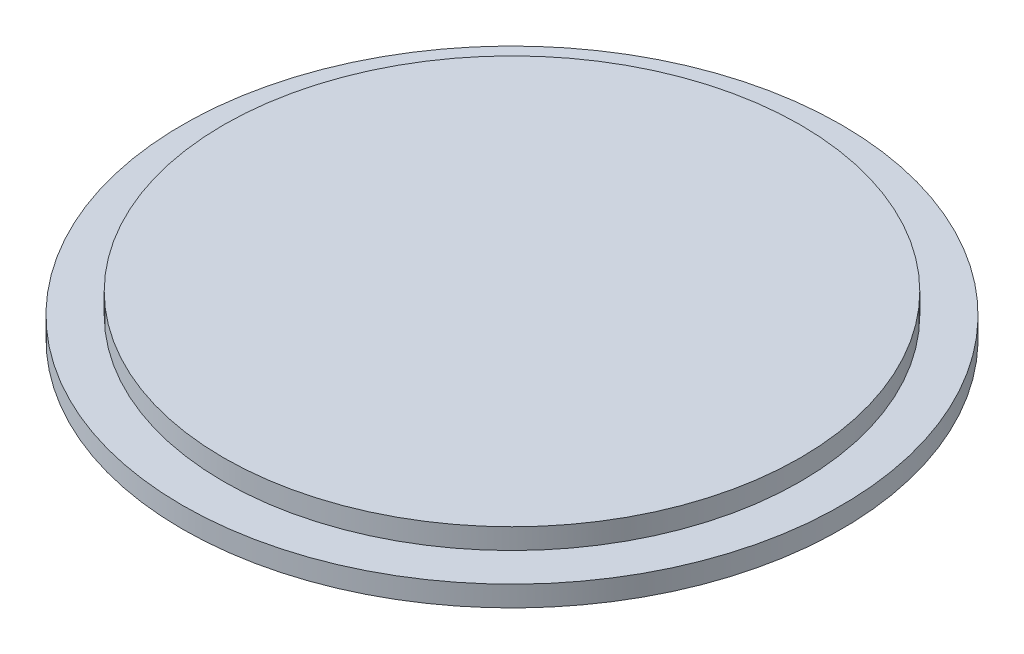
from build123d import *


with BuildPart() as part:
    # Эскиз1 → Повернуть1 (revolve)
    with BuildSketch(Plane.XY):
        Polygon((0, 0), (0, 2), (14, 2), (14, 1), (16, 1), (16, 0), align=None)
    revolve(axis=Axis((0, 0, 0), (0, 1, 0)))


solid = part.part
